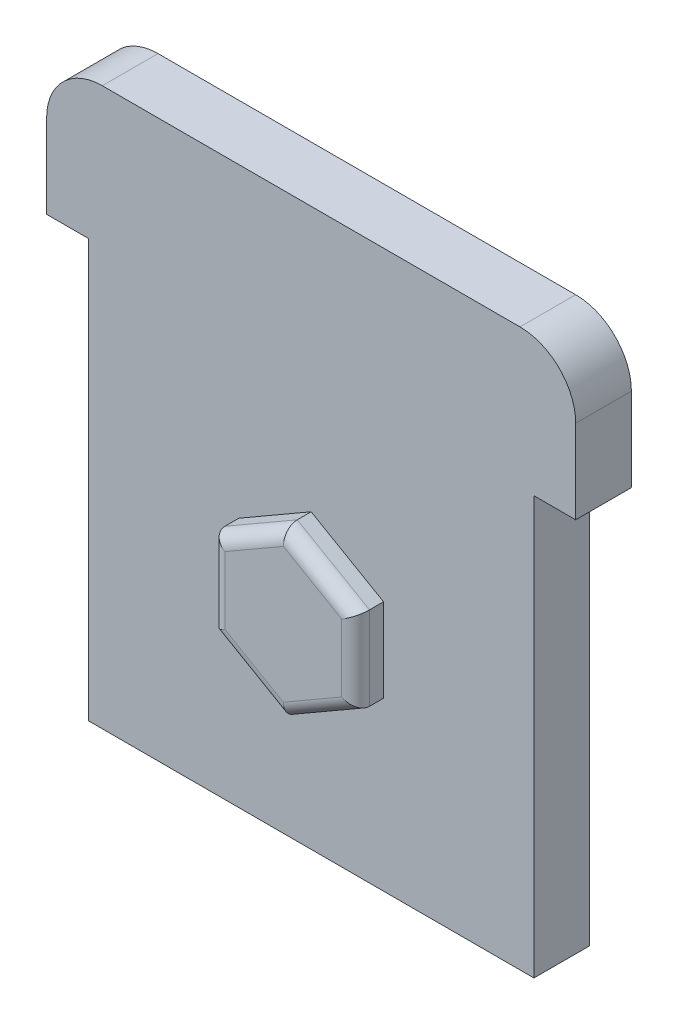
from build123d import *

# Parameters (mm, degrees)
CROQUIS1_W              = 16
CROQUIS1_H              = 15
SALIENTE_EXTRUIR3_DEPTH = 2
REDONDEO1_R             = 2
SALIENTE_EXTRUIR4_DEPTH = 1
REDONDEO2_R             = 0.5


with BuildPart() as part:
    # Croquis1 → Saliente-Extruir3 (new body)
    with BuildSketch(Plane.XY):
        Polygon((-1.5, 0), (0, 0), (16, 0), (17.5, 0), (17.5, 5), (-1.5, 5), align=None)
        with Locations((8, -7.5)):
            Rectangle(CROQUIS1_W, CROQUIS1_H)
    extrude(amount=SALIENTE_EXTRUIR3_DEPTH)

    # Redondeo1
    redondeo1_edges = [part.edges().sort_by_distance(p)[0] for p in [
        (-1.5, 5, 1),
        (17.5, 5, 1),
    ]]
    fillet(redondeo1_edges, radius=REDONDEO1_R)

    # Croquis3 → Saliente-Extruir4 (add)
    with BuildSketch(Plane.XY.offset(2)):
        Polygon((8, -4.5), (5.401923789, -6), (5.401923789, -9), (8, -10.5), (10.598076211, -9), (10.598076211, -6), align=None)
    extrude(amount=SALIENTE_EXTRUIR4_DEPTH)

    # Redondeo2
    redondeo2_edges = [part.edges().sort_by_distance(p)[0] for p in [
        (9.299038106, -5.25, 3),
        (6.700961894, -5.25, 3),
        (5.401923789, -7.5, 3),
        (6.700961894, -9.75, 3),
        (9.299038106, -9.75, 3),
        (10.598076211, -7.5, 3),
    ]]
    fillet(redondeo2_edges, radius=REDONDEO2_R)


solid = part.part
